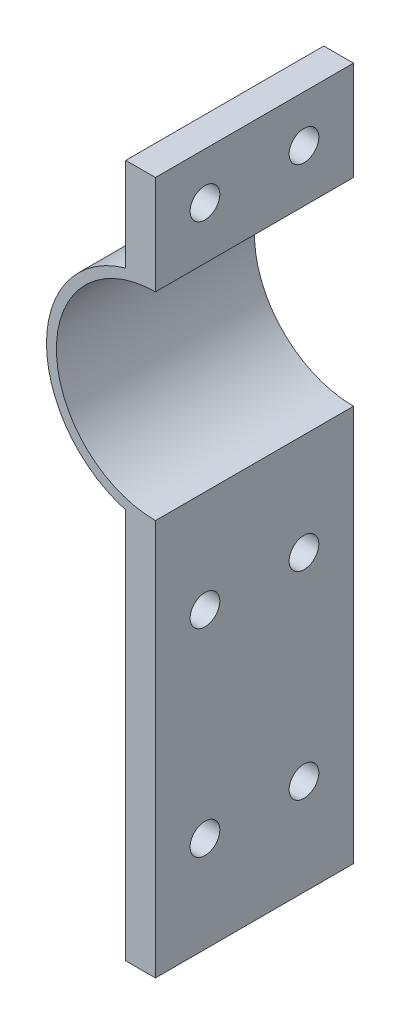
from build123d import *

# Parameters (mm, degrees)
EXTRUDE_1_DEPTH     = 20
SKETCH_2_R          = 1.5
CUT_EXTRUDE_1_DEPTH = 20


with BuildPart() as part:
    # 草图1 → 凸台-拉伸1 (new body)
    with BuildSketch(Plane.XY):
        with BuildLine():
            Line((-3, 20), (-3, 10.583005244))
            ThreePointArc((-3, 10.583005244), (-11, 0), (-3, -10.583005244))
            Line((-3, -10.583005244), (-3, -50))
            Line((-3, -50), (0, -50))
            Line((0, -50), (0, -10))
            ThreePointArc((0, -10), (-10, 0), (0, 10))
            Line((0, 10), (0, 20))
            Line((0, 20), (-3, 20))
        make_face()
    extrude(amount=EXTRUDE_1_DEPTH)

    # 草图2 → 切除-拉伸1 (cut)
    with BuildSketch(Plane.ZY.offset(3)):
        with Locations((5, 15.291502622)):
            Circle(SKETCH_2_R)
        with Locations((15, 15.291502622)):
            Circle(SKETCH_2_R)
        with Locations((5, -20.291502622)):
            Circle(SKETCH_2_R)
        with Locations((15, -20.291502622)):
            Circle(SKETCH_2_R)
        with Locations((15, -40.291502622)):
            Circle(SKETCH_2_R)
        with Locations((5, -40.291502622)):
            Circle(SKETCH_2_R)
    extrude(amount=-CUT_EXTRUDE_1_DEPTH, mode=Mode.SUBTRACT)


solid = part.part
